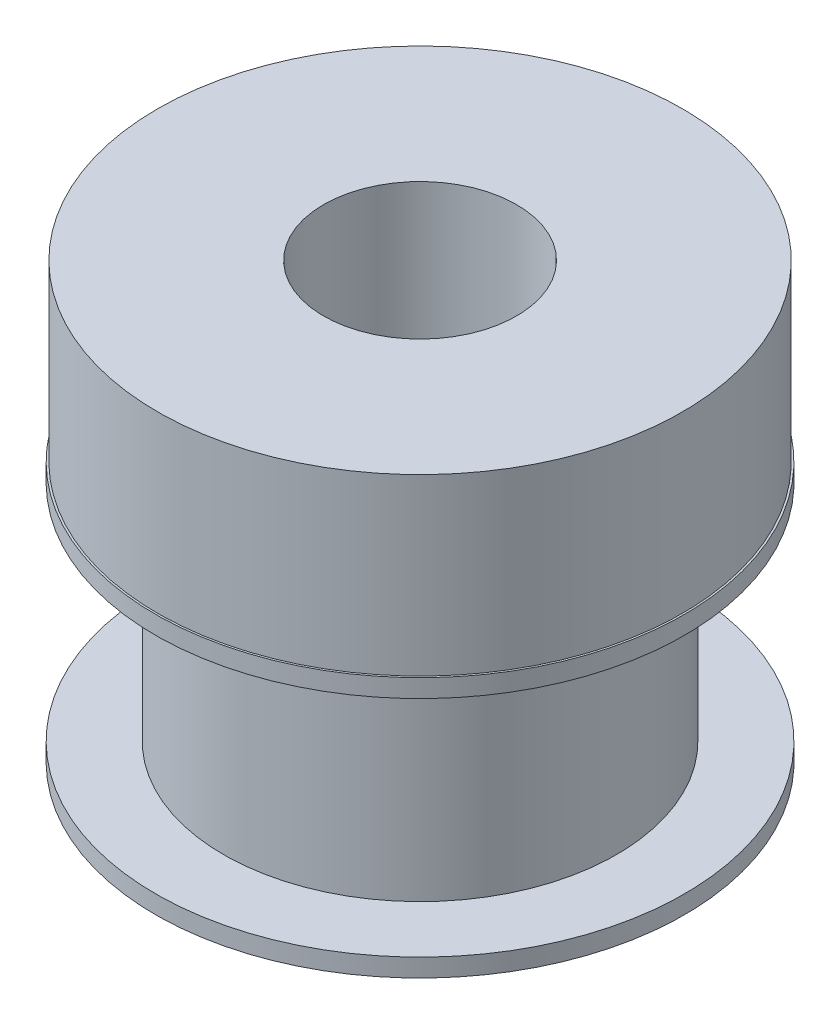
from build123d import *


with BuildPart() as part:
    # Sketch1 → Revolve1 (revolve)
    with BuildSketch(Plane.XY):
        Polygon((6.4643, 0.5969), (6.4643, 7.9629), (8.6995, 7.9629), (8.6995, 8.5598), (8.636, 8.5598), (8.636, 14.3002), (3.175, 14.3002), (3.175, 0), (8.6995, 0), (8.6995, 0.5969), align=None)
    revolve(axis=Axis((0, 26.682602177, 0), (0, -1, 0)))


solid = part.part
